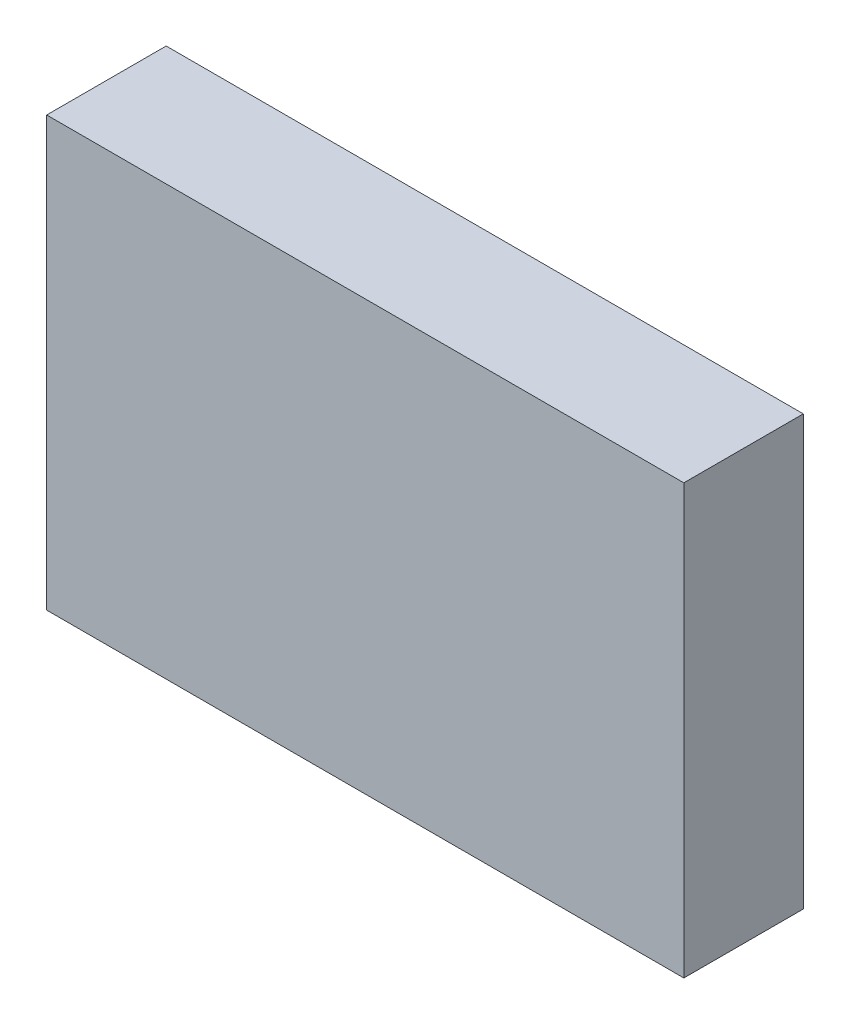
from build123d import *

# Parameters (mm, degrees)
SKETCH_1_W      = 520
SKETCH_1_H      = 350
EXTRUDE_1_DEPTH = 97.5


with BuildPart() as part:
    # 草图1 → 凸台-拉伸1 (new body)
    with BuildSketch(Plane.XY):
        Rectangle(SKETCH_1_W, SKETCH_1_H)
    extrude(amount=EXTRUDE_1_DEPTH)


solid = part.part
